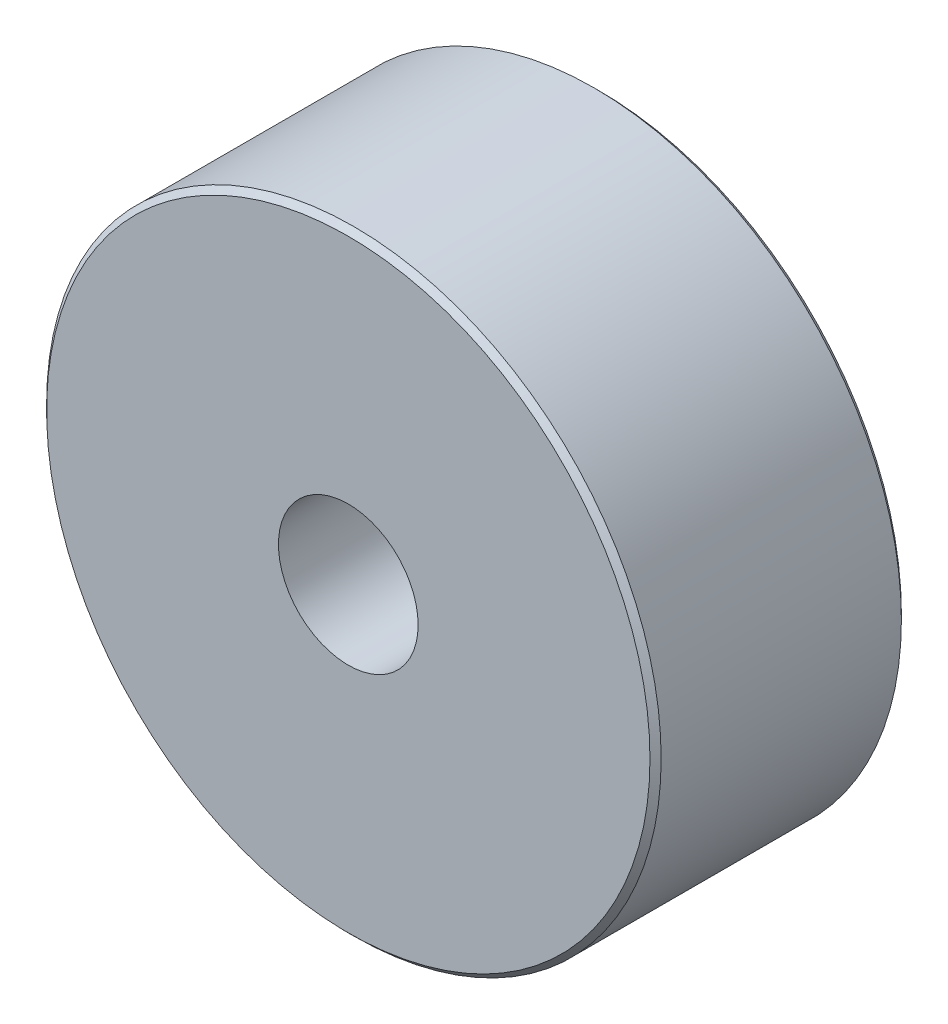
from build123d import *

# Parameters (mm, degrees)
ESQUISSE1_R        = 5.5
BOSS_EXTRU_1_DEPTH = 4.5
TROU_TARAUD_M31_D  = 2.5
CHANFREIN1_SIZE    = 0.1


with BuildPart() as part:
    # Esquisse1 → Boss.-Extru.1 (new body)
    with BuildSketch(Plane.XY):
        Circle(ESQUISSE1_R)
    extrude(amount=BOSS_EXTRU_1_DEPTH)

    # Trou taraudé M31 (through all)
    with Locations(Plane.XY.offset(4.5)):
        with Locations((0, 0)):
            Hole(TROU_TARAUD_M31_D / 2)

    # Chanfrein1
    chanfrein1_edges = [part.edges().sort_by_distance(p)[0] for p in [
        (-5.5, 0, 0),
        (-5.5, 0, 4.5),
    ]]
    chamfer(chanfrein1_edges, length=CHANFREIN1_SIZE)


solid = part.part
